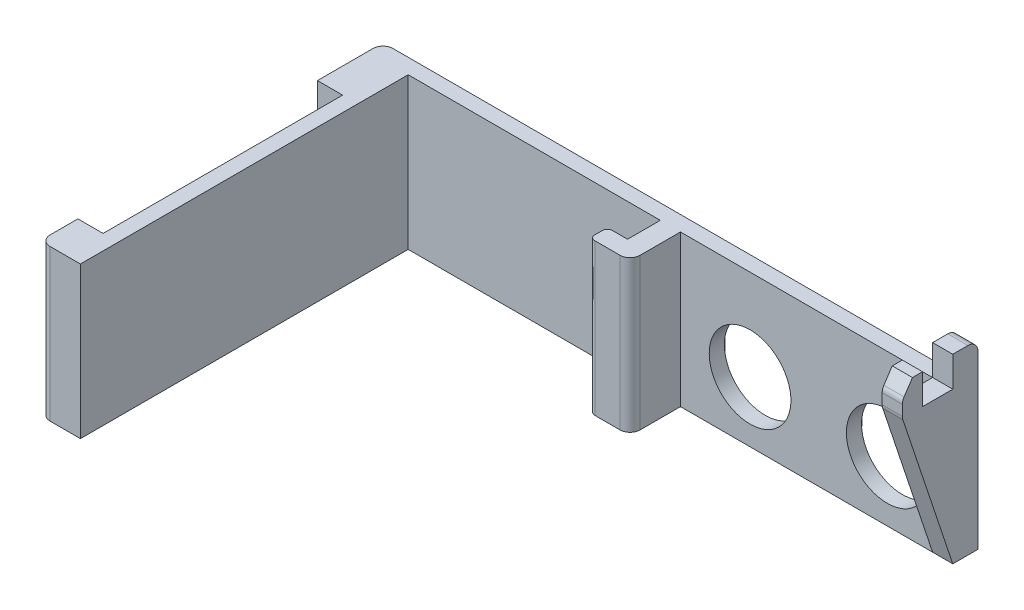
from build123d import *

# Parameters (mm, degrees)
BOSS_EXTRUDE1_DEPTH = 30
SKETCH2_W           = 2.5
SKETCH2_H           = 5
CUT_EXTRUDE1_DEPTH  = 5
SKETCH3_R           = 8.1
CUT_EXTRUDE2_DEPTH  = 71
BOSS_EXTRUDE5_DEPTH = 4
CUT_EXTRUDE3_DEPTH  = 2
FILLET1_R           = 2


with BuildPart() as part:
    # Sketch1 → Boss-Extrude1 (new body)
    with BuildSketch(Plane(origin=(0, 0, 0), x_dir=(1, 0, 0), z_dir=(0, 1, 0))):
        with BuildLine():
            Line((8, -65), (8, 0))
            Line((8, 0), (58, 0))
            Line((58, 0), (58, -6.5))
            Line((58, -6.5), (55, -6.5))
            ThreePointArc((55, -6.5), (54.292893219, -6.792893219), (54, -7.5))
            Line((54, -7.5), (54, -9))
            ThreePointArc((54, -9), (54.292893219, -9.707106781), (55, -10))
            Line((55, -10), (60, -10))
            ThreePointArc((60, -10), (61.414213562, -9.414213562), (62, -8))
            Line((62, -8), (62, 0))
            Line((62, 0), (116, 0))
            Line((116, 0), (116, 5))
            Line((116, 5), (0, 5))
            Line((0, 5), (0, -10))
            Line((0, -10), (5, -10))
            Line((5, -10), (5, -57.5))
            Line((5, -57.5), (0, -57.5))
            Line((0, -57.5), (0, -63))
            ThreePointArc((0, -63), (0.585786438, -64.414213562), (2, -65))
            Line((2, -65), (8, -65))
        make_face()
    extrude(amount=BOSS_EXTRUDE1_DEPTH)

    # Sketch2 → Cut-Extrude1 (cut)
    with BuildSketch(Plane.ZY):
        with Locations((8.75, 15)):
            Rectangle(SKETCH2_W, SKETCH2_H)
        with Locations((58.75, 15)):
            Rectangle(SKETCH2_W, SKETCH2_H)
    extrude(amount=-CUT_EXTRUDE1_DEPTH, mode=Mode.SUBTRACT)

    # Sketch3 → Cut-Extrude2 (cut, through all)
    with BuildSketch(Plane(origin=(0, 0, -5), x_dir=(-1, 0, 0), z_dir=(0, 0, -1))):
        with Locations((-103, 12)):
            Circle(SKETCH3_R)
        with Locations((-75.8, 12)):
            Circle(SKETCH3_R)
    extrude(amount=-CUT_EXTRUDE2_DEPTH, mode=Mode.SUBTRACT)

    # Sketch8 → Boss-Extrude5 (add)
    with BuildSketch(Plane(origin=(116, 0, 0), x_dir=(0, 0, -1), z_dir=(1, 0, 0))):
        with BuildLine():
            Line((-8, 36), (-9.664100589, 33.503849117))
            ThreePointArc((-9.664100589, 33.503849117), (-9.914184053, 32.974017022), (-10, 32.394448725))
            Line((-10, 32.394448725), (-10, 30.32455532))
            ThreePointArc((-10, 30.32455532), (-9.974174915, 30.004190834), (-9.897366596, 29.692099788))
            Line((-9.897366596, 29.692099788), (0, 0))
            Line((0, 0), (0, 30))
            Line((0, 30), (-6, 30))
            Line((-6, 30), (-6, 36))
            Line((-6, 36), (-8, 36))
        make_face()
        with BuildLine():
            Line((5, 30), (5, 34))
            ThreePointArc((5, 34), (4.414213562, 35.414213562), (3, 36))
            Line((3, 36), (0, 36))
            Line((0, 36), (0, 30))
            Line((0, 30), (5, 30))
        make_face()
    extrude(amount=-BOSS_EXTRUDE5_DEPTH)

    # Sketch10 → Cut-Extrude3 (cut)
    with BuildSketch(Plane(origin=(0, 0, -5), x_dir=(-1, 0, 0), z_dir=(0, 0, -1))):
        Polygon((-112, 30), (-113, 25), (-113, 1.5), (-65.8, 1.5), (-65.8, 26), (0, 26), (0, 30), align=None)
        with BuildLine():
            ThreePointArc((-93, 16), (-92.414213562, 17.414213562), (-91, 18))
            Line((-91, 18), (-87.8, 18))
            ThreePointArc((-87.8, 18), (-86.385786438, 17.414213562), (-85.8, 16))
            Line((-85.8, 16), (-85.8, 10))
            ThreePointArc((-85.8, 10), (-86.385786438, 8.585786438), (-87.8, 8))
            Line((-87.8, 8), (-91, 8))
            ThreePointArc((-91, 8), (-92.414213562, 8.585786438), (-93, 10))
            Line((-93, 10), (-93, 16))
        make_face(mode=Mode.SUBTRACT)
    extrude(amount=-CUT_EXTRUDE3_DEPTH, mode=Mode.SUBTRACT)

    # Fillet1
    fillet1_edges = [part.edges().sort_by_distance(p)[0] for p in [
        (0, 13, -5),
        (0, 28, -3),
    ]]
    fillet(fillet1_edges, radius=FILLET1_R)


solid = part.part
